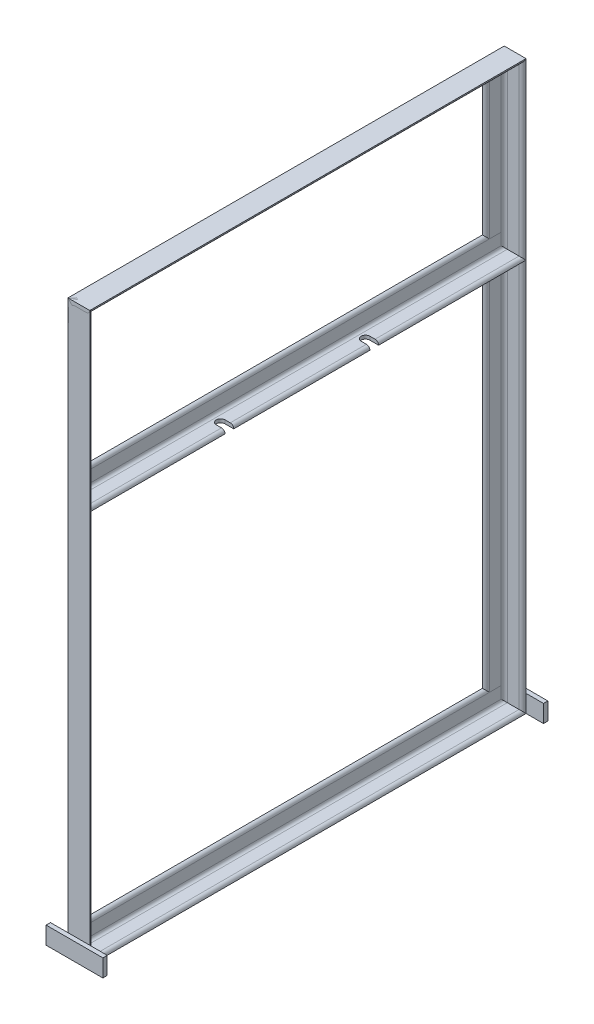
from build123d import *

# Parameters (mm, degrees)
STRUCTURAL_MEMBER4_DEPTH  = 500
STRUCTURAL_MEMBER5_DEPTH  = 500
CUT_EXTRUDE3_DEPTH        = 5
LPATTERN2_COUNT           = 2
LPATTERN2_PITCH           = 166
STRUCTURAL_MEMBER7_DEPTH  = 500
STRUCTURAL_MEMBER8_DEPTH  = 650
STRUCTURAL_MEMBER9_DEPTH  = 450
STRUCTURAL_MEMBER10_DEPTH = 200
SKETCH114_W               = 65
SKETCH114_H               = 20
BOSS_EXTRUDE6_DEPTH       = 5
SKETCH115_W               = 65
SKETCH115_H               = 20
BOSS_EXTRUDE7_DEPTH       = 5


with BuildPart() as part:
    # Sketch14 → Structural Member4 (new body)
    with BuildSketch(Plane(origin=(0, 700, -468.878865899), x_dir=(0, -1, 0), z_dir=(0, 0, 1))):
        with BuildLine():
            Line((0, 0), (0, 25))
            ThreePointArc((0, 25), (2.828427125, 23.828427125), (4, 21))
            Line((4, 21), (4, 7.5))
            ThreePointArc((4, 7.5), (5.025126266, 5.025126266), (7.5, 4))
            Line((7.5, 4), (21, 4))
            ThreePointArc((21, 4), (23.828427125, 2.828427125), (25, 0))
            Line((25, 0), (0, 0))
        make_face()
    extrude(amount=STRUCTURAL_MEMBER4_DEPTH)


with BuildPart() as body_2:
    # Sketch15 → Structural Member5 (new body)
    with BuildSketch(Plane(origin=(0, 500, 31.121134101), x_dir=(0, 1, 0), z_dir=(0, 0, -1))):
        with BuildLine():
            Line((0, 0), (0, 25))
            ThreePointArc((0, 25), (2.828427125, 23.828427125), (4, 21))
            Line((4, 21), (4, 7.5))
            ThreePointArc((4, 7.5), (5.025126266, 5.025126266), (7.5, 4))
            Line((7.5, 4), (21, 4))
            ThreePointArc((21, 4), (23.828427125, 2.828427125), (25, 0))
            Line((25, 0), (0, 0))
        make_face()
    extrude(amount=STRUCTURAL_MEMBER5_DEPTH)

    # Sketch23 → Cut-Extrude3 (cut)
    with BuildSketch(Plane(origin=(0, 500, 0), x_dir=(-1, 0, 0), z_dir=(0, -1, 0))):
        with BuildLine():
            Line((-25, 123.878865899), (-15, 123.878865899))
            ThreePointArc((-15, 123.878865899), (-10, 128.878865899), (-15, 133.878865899))
            Line((-15, 133.878865899), (-25, 133.878865899))
            Line((-25, 133.878865899), (-25, 123.878865899))
        make_face()
    cut_extrude3 = extrude(amount=-CUT_EXTRUDE3_DEPTH, mode=Mode.SUBTRACT)

    # LPattern2: Cut-Extrude3 ×2
    with Locations(*[(0, 0, -i * LPATTERN2_PITCH) for i in range(1, LPATTERN2_COUNT)]):
        add(cut_extrude3, mode=Mode.SUBTRACT)


with BuildPart() as body_3:
    # Sketch110 → Structural Member7 (new body)
    with BuildSketch(Plane(origin=(0, 50, 31.121134101), x_dir=(0, 1, 0), z_dir=(0, 0, -1))):
        with BuildLine():
            Line((0, 0), (0, 25))
            ThreePointArc((0, 25), (2.828427125, 23.828427125), (4, 21))
            Line((4, 21), (4, 7.5))
            ThreePointArc((4, 7.5), (5.025126266, 5.025126266), (7.5, 4))
            Line((7.5, 4), (21, 4))
            ThreePointArc((21, 4), (23.828427125, 2.828427125), (25, 0))
            Line((25, 0), (0, 0))
        make_face()
    extrude(amount=STRUCTURAL_MEMBER7_DEPTH)


with BuildPart() as body_4:
    # Sketch111 → Structural Member8 (new body)
    with BuildSketch(Plane(origin=(0, 700, 31.121134101), x_dir=(0, 0, -1), z_dir=(0, -1, 0))):
        with BuildLine():
            Line((0, 0), (0, 25))
            ThreePointArc((0, 25), (2.828427125, 23.828427125), (4, 21))
            Line((4, 21), (4, 7.5))
            ThreePointArc((4, 7.5), (5.025126266, 5.025126266), (7.5, 4))
            Line((7.5, 4), (21, 4))
            ThreePointArc((21, 4), (23.828427125, 2.828427125), (25, 0))
            Line((25, 0), (0, 0))
        make_face()
    extrude(amount=STRUCTURAL_MEMBER8_DEPTH)


with BuildPart() as body_5:
    # Sketch112 → Structural Member9 (new body)
    with BuildSketch(Plane(origin=(0, 50, -468.878865899), x_dir=(0, 0, 1), z_dir=(0, 1, 0))):
        with BuildLine():
            Line((0, 0), (0, 25))
            ThreePointArc((0, 25), (2.828427125, 23.828427125), (4, 21))
            Line((4, 21), (4, 7.5))
            ThreePointArc((4, 7.5), (5.025126266, 5.025126266), (7.5, 4))
            Line((7.5, 4), (21, 4))
            ThreePointArc((21, 4), (23.828427125, 2.828427125), (25, 0))
            Line((25, 0), (0, 0))
        make_face()
    extrude(amount=STRUCTURAL_MEMBER9_DEPTH)


with BuildPart() as body_6:
    # Sketch113 → Structural Member10 (new body)
    with BuildSketch(Plane(origin=(0, 500, -468.878865899), x_dir=(0, 0, 1), z_dir=(0, 1, 0))):
        with BuildLine():
            Line((0, 0), (0, 25))
            ThreePointArc((0, 25), (2.828427125, 23.828427125), (4, 21))
            Line((4, 21), (4, 7.5))
            ThreePointArc((4, 7.5), (5.025126266, 5.025126266), (7.5, 4))
            Line((7.5, 4), (21, 4))
            ThreePointArc((21, 4), (23.828427125, 2.828427125), (25, 0))
            Line((25, 0), (0, 0))
        make_face()
    extrude(amount=STRUCTURAL_MEMBER10_DEPTH)


with BuildPart() as body_7:
    # Sketch114 → Boss-Extrude6 (new body)
    with BuildSketch(Plane.XY.offset(31.121134101)):
        with Locations((12.5, 60)):
            Rectangle(SKETCH114_W, SKETCH114_H)
    extrude(amount=BOSS_EXTRUDE6_DEPTH)


with BuildPart() as body_8:
    # Sketch115 → Boss-Extrude7 (new body)
    with BuildSketch(Plane(origin=(0, 0, -468.878865899), x_dir=(-1, 0, 0), z_dir=(0, 0, -1))):
        with Locations((-12.5, 60)):
            Rectangle(SKETCH115_W, SKETCH115_H)
    extrude(amount=BOSS_EXTRUDE7_DEPTH)


solid = Compound([part.part, body_2.part, body_3.part, body_4.part, body_5.part, body_6.part, body_7.part, body_8.part])
